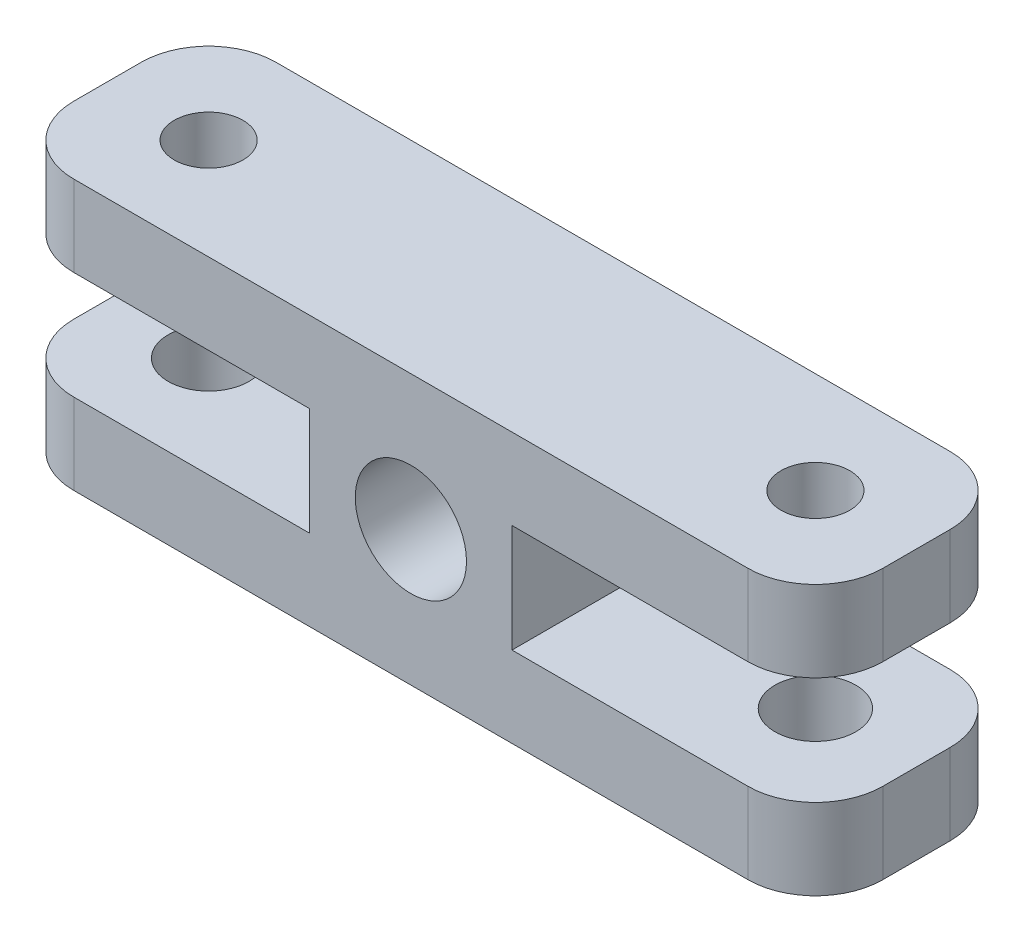
from build123d import *

# Parameters (mm, degrees)
SKETCH_1_W              = 120
SKETCH_1_H              = 40
EXTRUDE_1_DEPTH         = 15
SKETCH_5_R              = 6
CUT_EXTRUDE_2_DEPTH     = 20
M18X1_5_1_D             = 16.5
SKETCH_8_W              = 45
SKETCH_8_H              = 16
CUT_EXTRUDE_3_DEPTH     = 31
FILLET_1_R              = 10
HOLE_WIZARD_M12_1_D     = 10.2
HOLE_WIZARD_M12_1_DEPTH = 15
HOLE_WIZARD_M12_1_TIP   = 3.064389157


with BuildPart() as part:
    # 草图1 → 凸台-拉伸1 (new body, symmetric)
    with BuildSketch(Plane.XY):
        Rectangle(SKETCH_1_W, SKETCH_1_H)
    extrude(amount=EXTRUDE_1_DEPTH, both=True)

    # 草图5 → 切除-拉伸2 (cut)
    with BuildSketch(Plane(origin=(0, -20, 0), x_dir=(-1, 0, 0), z_dir=(0, -1, 0))):
        with Locations((45, 0)):
            Circle(SKETCH_5_R)
        with Locations((-45, 0)):
            Circle(SKETCH_5_R)
    extrude(amount=-CUT_EXTRUDE_2_DEPTH, mode=Mode.SUBTRACT)

    # M18x1.5 螺纹孔1 (through all)
    with Locations(Plane.XY.offset(15)):
        with Locations((0, 0)):
            Hole(M18X1_5_1_D / 2)

    # 草图8 → 切除-拉伸3 (cut, through all)
    with BuildSketch(Plane.XY.offset(15)):
        with Locations((-37.5, 0)):
            Rectangle(SKETCH_8_W, SKETCH_8_H)
        with Locations((37.5, 0)):
            Rectangle(SKETCH_8_W, SKETCH_8_H)
    extrude(amount=-CUT_EXTRUDE_3_DEPTH, mode=Mode.SUBTRACT)

    # 圆角1
    fillet_1_edges = [part.edges().sort_by_distance(p)[0] for p in [
        (-60, 14, 15),
        (-60, -14, -15),
        (-60, -14, 15),
        (60, -14, 15),
        (60, 14, -15),
        (60, 14, 15),
        (-60, 14, -15),
        (60, -14, -15),
    ]]
    fillet(fillet_1_edges, radius=FILLET_1_R)

    # M12 螺纹孔1
    with Locations(Plane(origin=(0, 20, 0), x_dir=(1, 0, 0), z_dir=(0, 1, 0))):
        with Locations((-45, 0), (45, 0)):
            Hole(HOLE_WIZARD_M12_1_D / 2, depth=HOLE_WIZARD_M12_1_DEPTH)
            with Locations((0, 0, -(HOLE_WIZARD_M12_1_DEPTH + HOLE_WIZARD_M12_1_TIP / 2))):  # 118° drill point
                Cone(0, HOLE_WIZARD_M12_1_D / 2, HOLE_WIZARD_M12_1_TIP, mode=Mode.SUBTRACT)


solid = part.part
